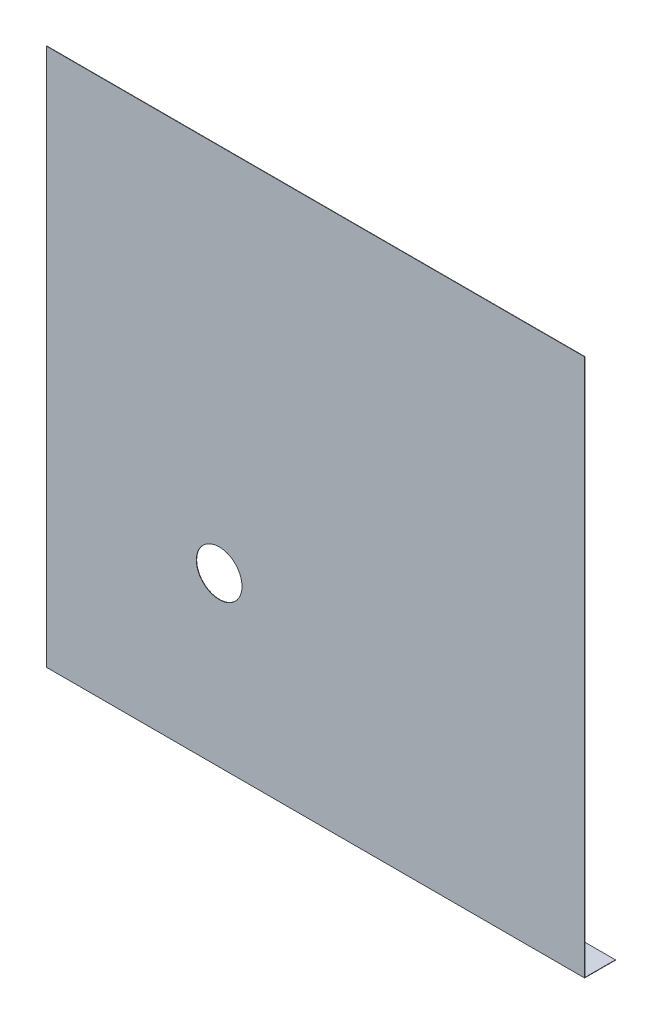
from build123d import *

# Parameters (mm, degrees)
BOSS_EXTRUDE1_DEPTH = 530
SKETCH3_R           = 22.5
CUT_EXTRUDE1_DEPTH  = 530


with BuildPart() as part:
    # Sketch2 → Boss-Extrude1 (new body)
    with BuildSketch(Plane(origin=(0, 0, 0), x_dir=(0, 0, -1), z_dir=(1, 0, 0))):
        Polygon((0, 530), (0.35, 530), (0.35, 0.35), (30.35, 0.35), (30.35, 0), (0, 0), align=None)
    extrude(amount=BOSS_EXTRUDE1_DEPTH)

    # Sketch3 → Cut-Extrude1 (cut)
    with BuildSketch(Plane(origin=(0, 0, -0.35), x_dir=(-1, 0, 0), z_dir=(0, 0, -1))):
        with Locations((-170, 165.35)):
            Circle(SKETCH3_R)
    extrude(amount=-CUT_EXTRUDE1_DEPTH, mode=Mode.SUBTRACT)


solid = part.part
